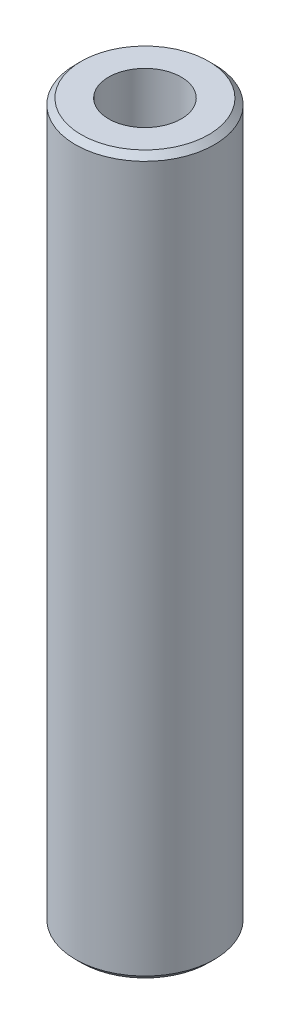
from build123d import *

# Parameters (mm, degrees)
CROQUIS2_R                = 4.7625
SALIENTE_EXTRUIR1_DEPTH   = 24.5872
CHAFL_N1_SIZE             = 0.396875
CLEARANCE_HOLE_DEPTH      = 26.493003282
CLEARANCE_HOLE_DEPTH_BACK = 26.493003282
CROQUIS4_R                = 2.4892


with BuildPart() as part:
    # Croquis2 → Saliente-Extruir1 (new, symmetric)
    with BuildSketch(Plane(origin=(0, 0, 0), x_dir=(1, 0, 0), z_dir=(0, 1, 0))):
        Circle(CROQUIS2_R)
    extrude(amount=SALIENTE_EXTRUIR1_DEPTH, both=True)

    # Chaflán1
    chafl_n1_edges = [part.edges().sort_by_distance(p)[0] for p in [
        (-4.7625, -24.5872, 0),
        (-4.7625, 24.5872, 0),
    ]]
    chamfer(chafl_n1_edges, length=CHAFL_N1_SIZE)

    # Croquis4 → Clearance Hole (cut, two sides: drawn at the far end of the back side and taken through both)
    with BuildSketch(Plane(origin=(0, 0, 0), x_dir=(1, 0, 0), z_dir=(0, 1, 0)).offset(-CLEARANCE_HOLE_DEPTH_BACK)):
        Circle(CROQUIS4_R)
    extrude(amount=CLEARANCE_HOLE_DEPTH + CLEARANCE_HOLE_DEPTH_BACK, mode=Mode.SUBTRACT)


solid = part.part
